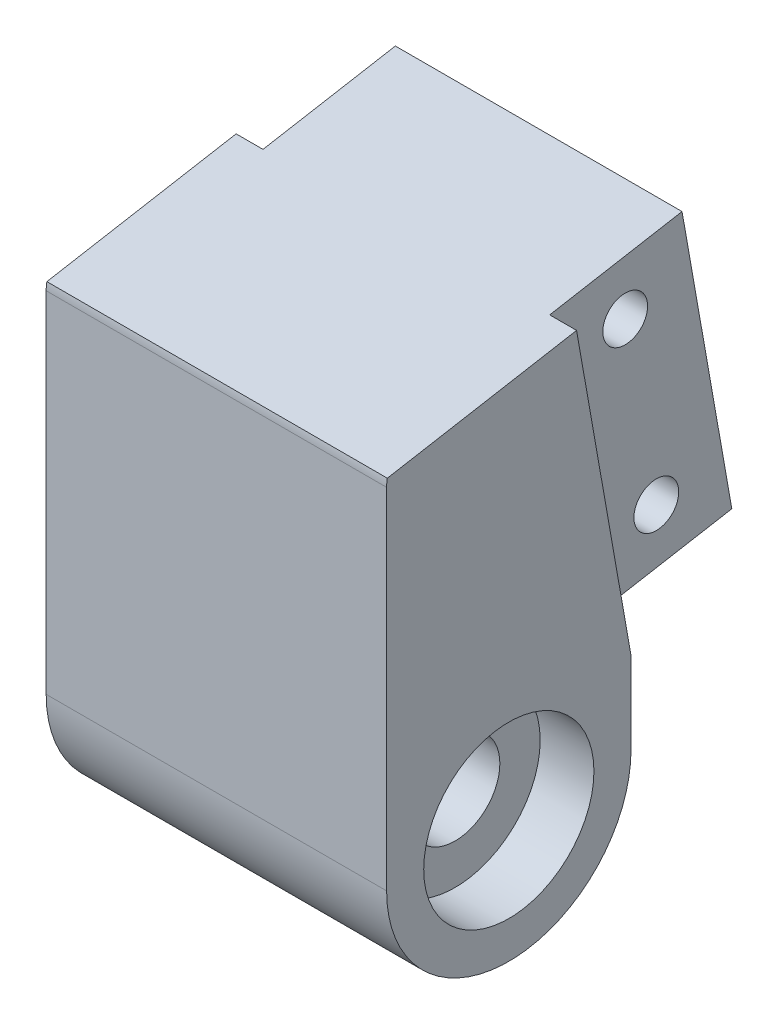
from build123d import *

# Parameters (mm, degrees)
SKETCH1_R           = 5
BOSS_EXTRUDE1_DEPTH = 38
SKETCH2_R           = 9.5
CUT_EXTRUDE1_DEPTH  = 6
SKETCH3_W           = 38
SKETCH3_H           = 38
SKETCH3_W_2         = 32
SKETCH3_H_2         = 32
CUT_EXTRUDE2_DEPTH  = 15
SKETCH4_W           = 38
SKETCH4_H           = 3
CUT_EXTRUDE3_DEPTH  = 31.815956095
SKETCH6_R           = 2.5
CUT_EXTRUDE4_DEPTH  = 36


with BuildPart() as part:
    # Sketch1 → Boss-Extrude1 (new body)
    with BuildSketch(Plane(origin=(0, 0, 0), x_dir=(0, 0, -1), z_dir=(1, 0, 0))):
        with BuildLine():
            Line((18.027765774, -4.140855059), (49.663434225, 1.437366842))
            Line((49.663434225, 1.437366842), (56.262064976, -35.985327773))
            Line((56.262064976, -35.985327773), (41.489948681, -38.590050438))
            Line((41.489948681, -38.590050438), (41.489948681, -47.702008996))
            ThreePointArc((41.489948681, -47.702008996), (27.850151899, -61.341805778), (14.210355117, -47.702008996))
            Line((14.210355117, -47.702008996), (14.210355117, -8.690267924))
            ThreePointArc((14.210355117, -8.690267924), (15.291135012, -5.720849566), (18.027765774, -4.140855059))
        make_face()
        with Locations((27.850151899, -47.702008996)):
            Circle(SKETCH1_R, mode=Mode.SUBTRACT)
    extrude(amount=BOSS_EXTRUDE1_DEPTH)

    # Sketch2 → Cut-Extrude1 (cut)
    with BuildSketch(Plane(origin=(38, 0, 0), x_dir=(0, 0, -1), z_dir=(1, 0, 0))):
        with Locations((27.850151899, -47.702008996)):
            Circle(SKETCH2_R)
    cut_extrude1 = extrude(amount=-CUT_EXTRUDE1_DEPTH, mode=Mode.SUBTRACT)

    # Mirror1: Cut-Extrude1 across plane
    add(cut_extrude1.mirror(Plane(origin=(19, 0, 0), x_dir=(0, 0, 1), z_dir=(1, 0, 0))), mode=Mode.SUBTRACT)

    # Sketch3 → Cut-Extrude2 (cut)
    with BuildSketch(Plane(origin=(0, 8.536289359, -48.411702651), x_dir=(-1, 0, 0), z_dir=(0, 0.173648178, -0.984807753))):
        with Locations((-19, -26.20843484)):
            Rectangle(SKETCH3_W, SKETCH3_H)
        with Locations((-19, -26.20843484)):
            Rectangle(SKETCH3_W_2, SKETCH3_H_2, mode=Mode.SUBTRACT)
    extrude(amount=-CUT_EXTRUDE2_DEPTH, mode=Mode.SUBTRACT)

    # Sketch4 → Cut-Extrude3 (cut, through all)
    with BuildSketch(Plane(origin=(0, 5.931566694, -33.639586356), x_dir=(-1, 0, 0), z_dir=(0, 0.173648178, -0.984807753))):
        with Locations((-19, -8.70843484)):
            Rectangle(SKETCH4_W, SKETCH4_H)
    extrude(amount=-CUT_EXTRUDE3_DEPTH, mode=Mode.SUBTRACT)

    # Sketch6 → Cut-Extrude4 (cut, through all)
    with BuildSketch(Plane(origin=(35, 0, 0), x_dir=(0, 0, -1), z_dir=(1, 0, 0))):
        with Locations((43.840209676, -8.728264268)):
            Circle(SKETCH6_R)
        with Locations((47.31317323, -28.424419328)):
            Circle(SKETCH6_R)
    extrude(amount=-CUT_EXTRUDE4_DEPTH, mode=Mode.SUBTRACT)


solid = part.part
